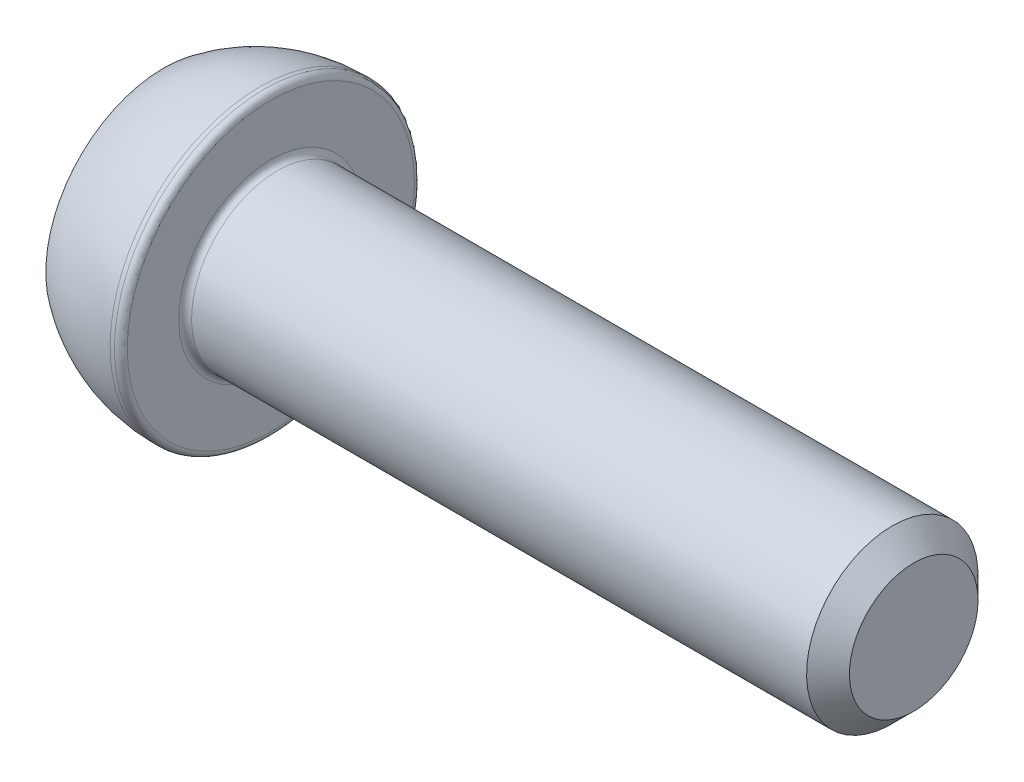
from build123d import *

# Parameters (mm, degrees)
CUT_EXTRUDE_1_DEPTH = 3
FILLET_1_R          = 0.3
CHAMFER_1_SIZE      = 1


with BuildPart() as part:
    # Эскиз1 → Повернуть1 (revolve)
    with BuildSketch(Plane.XY):
        with BuildLine():
            Line((0, 0), (0, 5.5))
            ThreePointArc((0, 5.5), (2.128291755, 6.615124735), (4.5, 7))
            Line((4.5, 7), (5, 7))
            Line((5, 7), (5, 4))
            Line((5, 4), (35, 4))
            Line((35, 4), (35, 0))
            Line((35, 0), (0, 0))
        make_face()
    revolve(axis=Axis((35, 0, 0), (-1, 0, 0)))

    # Эскиз2 → Вырез-Вытянуть1 (cut)
    with BuildSketch(Plane.ZY):
        Polygon((1.732050808, 3), (-1.732050808, 3), (-3.464101615, 0), (-1.732050808, -3), (1.732050808, -3), (3.464101615, 0), align=None)
    extrude(amount=-CUT_EXTRUDE_1_DEPTH, mode=Mode.SUBTRACT)

    # Скругление1
    fillet_1_edges = [part.edges().sort_by_distance(p)[0] for p in [
        (5, -4, 0),
        (5, -7, 0),
    ]]
    fillet(fillet_1_edges, radius=FILLET_1_R)

    # Фаска1
    chamfer_1_edges = [part.edges().sort_by_distance(p)[0] for p in [
        (35, -4, 0),
    ]]
    chamfer(chamfer_1_edges, length=CHAMFER_1_SIZE)


solid = part.part
